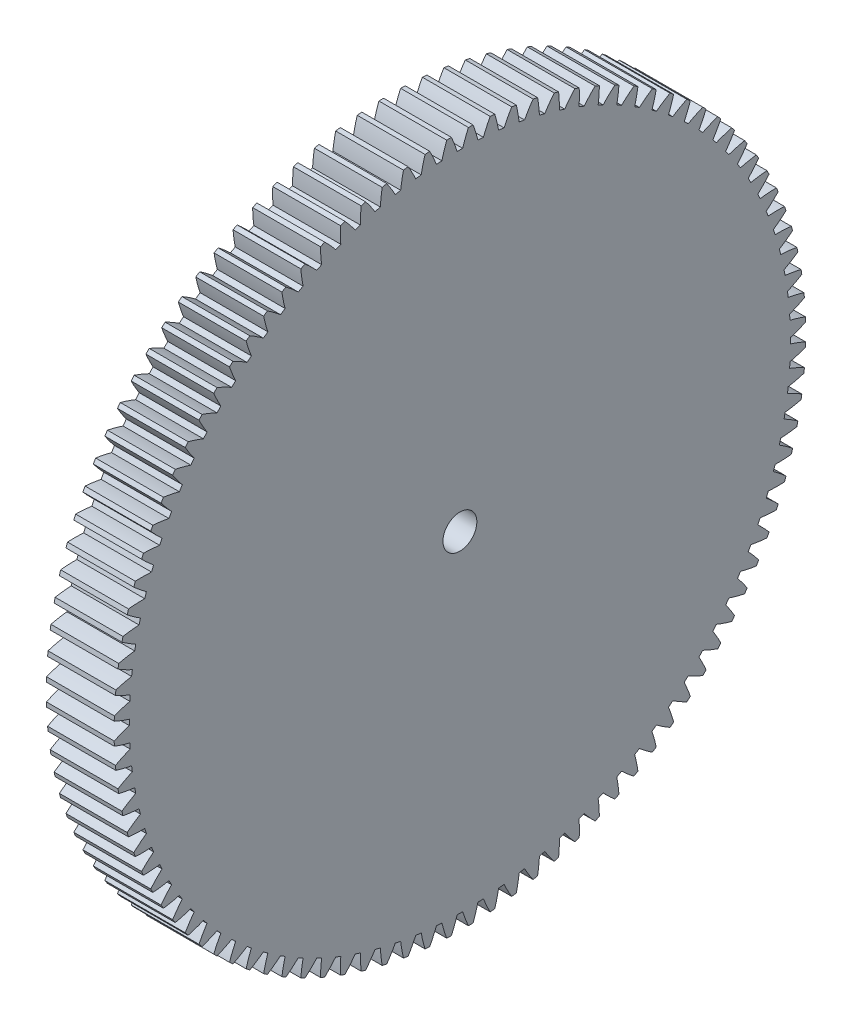
from build123d import *

# Parameters (mm, degrees)
BASPROSKE_W     = 20
BASPROSKE_H     = 102
TOOTHCUT_DEPTH  = 146.629667307
TEETHCUTS_COUNT = 100
TEETHCUTS_ANGLE = 356.4
BORSKE_R        = 5
BORE_DEPTH      = 50.0000508


with BuildPart() as part:
    # BasProSke → Base-Revolve (revolve)
    with BuildSketch(Plane(origin=(0, 0, 0), x_dir=(1, 0, 0), z_dir=(0, 1, 0)), mode=Mode.PRIVATE) as base_revolve_sk:
        with Locations((10, 51)):
            Rectangle(BASPROSKE_W, BASPROSKE_H)
    revolve(base_revolve_sk.sketch.rotate(Axis((-10, 0, 0), (1, 0, 0)), 180), axis=Axis((-10, 0, 0), (1, 0, 0)))

    # TooCutSke → ToothCut (cut, through all)
    with BuildSketch(Plane(origin=(0, 0, 0), x_dir=(0, 0, -1), z_dir=(1, 0, 0))):
        with BuildLine():
            ThreePointArc((0.814317866, 97.495599323), (0, 97.499), (-0.814317866, 97.495599323))
            ThreePointArc((-0.814317866, 97.495599323), (-1.605159394, 99.770655719), (-2.531497118, 101.993988879))
            ThreePointArc((-2.531497118, 101.993988879), (0, 102.0254), (2.531497118, 101.993988879))
            ThreePointArc((2.531497118, 101.993988879), (1.605159394, 99.770655719), (0.814317866, 97.495599323))
        make_face()
    toothcut = extrude(amount=TOOTHCUT_DEPTH, mode=Mode.SUBTRACT)

    # TeethCuts: ToothCut ×100 about axis
    teethcuts_axis = Axis((-10, 0, 0), (1, 0, 0))
    for i in range(1, TEETHCUTS_COUNT):
        add(toothcut.rotate(teethcuts_axis, i * TEETHCUTS_ANGLE / (TEETHCUTS_COUNT - 1)), mode=Mode.SUBTRACT)

    # BorSke → Bore (cut, symmetric)
    with BuildSketch(Plane(origin=(0, 0, 0), x_dir=(0, 0, -1), z_dir=(1, 0, 0))):
        with Locations(Location((0, 0, 0), (0, 0, 180))):
            Circle(BORSKE_R)
    extrude(amount=BORE_DEPTH, both=True, mode=Mode.SUBTRACT)


solid = part.part
